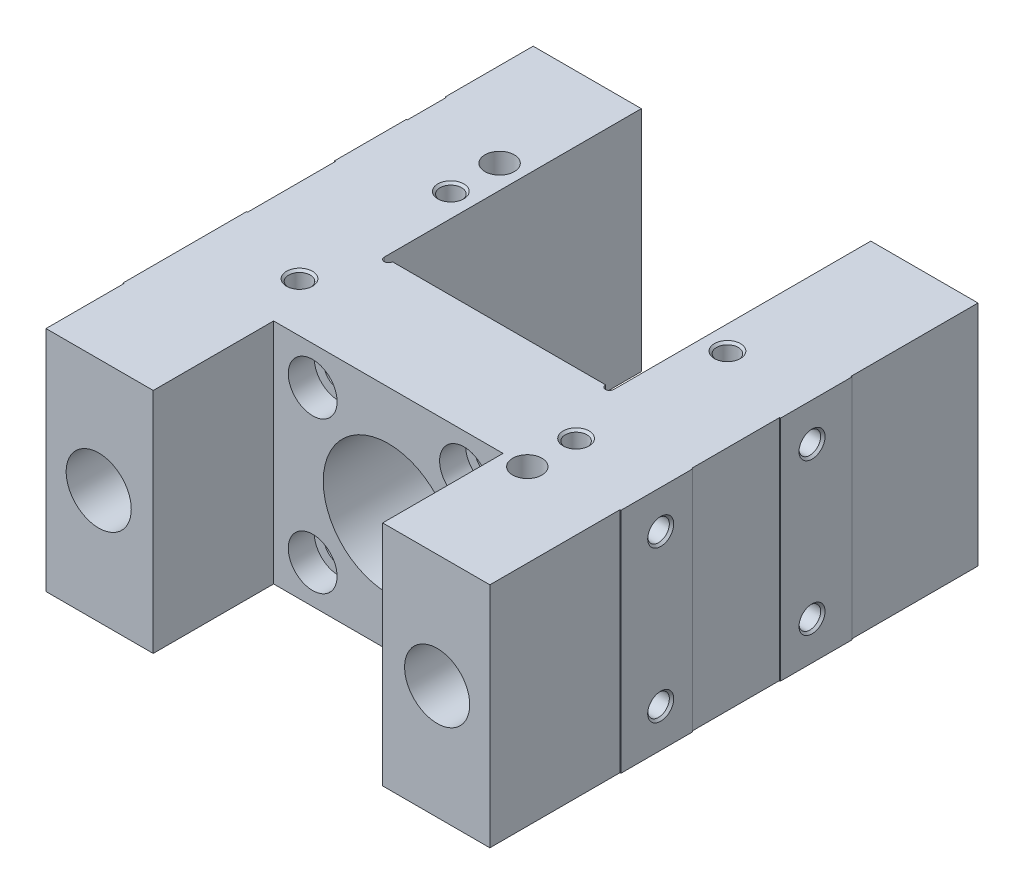
from build123d import *

# Parameters (mm, degrees)
BOSS_EXTRUDE1_DEPTH      = 35
BOSS_EXTRUDE1_DEPTH_BACK = 35
SKETCH2_W                = 36
SKETCH2_H                = 20
HOLE1_D                  = 6.647
HOLE1_DEPTH              = 19.414509714
HOLE1_CSINK_D            = 8
HOLE1_CSINK_ANGLE        = 90
HOLE1_TIP                = 1.91882362
HOLE2_D                  = 6.647
HOLE2_DEPTH              = 19.414509714
HOLE2_CSINK_D            = 8
HOLE2_CSINK_ANGLE        = 90
HOLE2_TIP                = 1.91882362
HOLE3_D                  = 6.647
HOLE3_DEPTH              = 19.414509714
HOLE3_CSINK_D            = 8
HOLE3_CSINK_ANGLE        = 90
HOLE3_TIP                = 1.91882362
SKETCH26_R               = 10
CUT_EXTRUDE1_DEPTH       = 150
SKETCH27_R               = 10
CUT_EXTRUDE2_DEPTH       = 150
CUT_EXTRUDE3_DEPTH       = 70
CUT_EXTRUDE3_DEPTH_BACK  = 70
SKETCH28_W               = 177
SKETCH28_H               = 190
SKETCH29_R               = 4.5
CUT_EXTRUDE4_DEPTH       = 17.5


with BuildPart() as part:
    # Sketch1 → Boss-Extrude1 (new, two sides: drawn at the far end of the back side and taken through both)
    with BuildSketch(Plane(origin=(0, 0, 0), x_dir=(1, 0, 0), z_dir=(0, 1, 0)).offset(-BOSS_EXTRUDE1_DEPTH_BACK)):
        with BuildLine():
            Line((-68.5, -71), (-35.25, -71))
            Line((-35.25, -71), (-35.25, -34))
            Line((-35.25, -34), (35.25, -34))
            Line((35.25, -34), (35.25, -71))
            Line((35.25, -71), (68.5, -71))
            Line((68.5, -71), (68.5, 79))
            Line((68.5, 79), (35.25, 79))
            Line((35.25, 79), (35.25, 0))
            ThreePointArc((35.25, 0), (34, -1.25), (32.75, 0))
            Line((32.75, 0), (-32.75, 0))
            ThreePointArc((-32.75, 0), (-34, -1.25), (-35.25, 0))
            Line((-35.25, 0), (-35.25, 79))
            Line((-35.25, 79), (-68.5, 79))
            Line((-68.5, 79), (-68.5, -71))
        make_face()
    extrude(amount=BOSS_EXTRUDE1_DEPTH + BOSS_EXTRUDE1_DEPTH_BACK)

    # Sketch2 → Cut-Revolve1 (revolve, cut)
    with BuildSketch(Plane(origin=(0, 0, 0), x_dir=(0, 0, -1), z_dir=(1, 0, 0))):
        with Locations((-17, 10)):
            Rectangle(SKETCH2_W, SKETCH2_H)
    revolve(axis=Axis((0, 0, -1), (0, 0, 1)), mode=Mode.SUBTRACT)

    # Sketch3 → Cut-Revolve2 (revolve, cut)
    with BuildSketch(Plane(origin=(-23.25, 0, 0), x_dir=(0, 0, -1), z_dir=(1, 0, 0))):
        Polygon((-34, 23.25), (-34, 30.75), (-26, 30.75), (-26, 27.75), (0, 27.75), (0, 23.25), align=None)
    revolve(axis=Axis((-23.25, 23.25, 0), (0, 0, 1)), mode=Mode.SUBTRACT)

    # Sketch4 → Cut-Revolve3 (revolve, cut)
    with BuildSketch(Plane(origin=(-23.25, 0, 0), x_dir=(0, 0, -1), z_dir=(1, 0, 0))):
        Polygon((-34, -23.25), (-34, -15.75), (-26, -15.75), (-26, -18.75), (0, -18.75), (0, -23.25), align=None)
    revolve(axis=Axis((-23.25, -23.25, 0), (0, 0, 1)), mode=Mode.SUBTRACT)

    # Sketch5 → Cut-Revolve4 (revolve, cut)
    with BuildSketch(Plane(origin=(23.25, 0, 0), x_dir=(0, 0, -1), z_dir=(1, 0, 0))):
        Polygon((-34, 23.25), (-34, 30.75), (-26, 30.75), (-26, 27.75), (0, 27.75), (0, 23.25), align=None)
    revolve(axis=Axis((23.25, 23.25, 0), (0, 0, 1)), mode=Mode.SUBTRACT)

    # Sketch6 → Cut-Revolve5 (revolve, cut)
    with BuildSketch(Plane(origin=(23.25, 0, 0), x_dir=(0, 0, -1), z_dir=(1, 0, 0))):
        Polygon((-34, -23.25), (-34, -15.75), (-26, -15.75), (-26, -18.75), (0, -18.75), (0, -23.25), align=None)
    revolve(axis=Axis((23.25, -23.25, 0), (0, 0, 1)), mode=Mode.SUBTRACT)

    # Hole1
    with Locations(Plane(origin=(0, 35, 0), x_dir=(1, 0, 0), z_dir=(0, 1, 0))):
        with Locations((42.5, -18.8)):
            CounterSinkHole(HOLE1_D / 2, HOLE1_CSINK_D / 2, depth=HOLE1_DEPTH, counter_sink_angle=HOLE1_CSINK_ANGLE)
            with Locations((0, 0, -(HOLE1_DEPTH + HOLE1_TIP / 2))):  # 120° drill point
                Cone(0, HOLE1_D / 2, HOLE1_TIP, mode=Mode.SUBTRACT)

    # Hole2
    with Locations(Plane(origin=(0, 35, 0), x_dir=(1, 0, 0), z_dir=(0, 1, 0))):
        with Locations((-42.5, -18.8)):
            CounterSinkHole(HOLE2_D / 2, HOLE2_CSINK_D / 2, depth=HOLE2_DEPTH, counter_sink_angle=HOLE2_CSINK_ANGLE)
            with Locations((0, 0, -(HOLE2_DEPTH + HOLE2_TIP / 2))):  # 120° drill point
                Cone(0, HOLE2_D / 2, HOLE2_TIP, mode=Mode.SUBTRACT)

    # Sketch11 → Cut-Revolve6 (revolve, cut)
    with BuildSketch(Plane.XY.offset(18.8)):
        Polygon((48.5, 23.25), (50.41882362, 26.5735), (67.8235, 26.5735), (68.5, 27.25), (68.5, 23.25), align=None)
    revolve(axis=Axis((68.5, 23.25, 18.8), (-1, 0, 0)), mode=Mode.SUBTRACT)

    # Sketch12 → Cut-Revolve7 (revolve, cut)
    with BuildSketch(Plane.XY.offset(18.8)):
        Polygon((48.5, -23.25), (50.41882362, -19.9265), (67.8235, -19.9265), (68.5, -19.25), (68.5, -23.25), align=None)
    revolve(axis=Axis((68.5, -23.25, 18.8), (-1, 0, 0)), mode=Mode.SUBTRACT)

    # Sketch13 → Cut-Revolve8 (revolve, cut)
    with BuildSketch(Plane.XY.offset(18.8)):
        Polygon((-68.5, 23.25), (-68.5, 27.25), (-67.8235, 26.5735), (-50.41882362, 26.5735), (-48.5, 23.25), align=None)
    revolve(axis=Axis((-48.5, 23.25, 18.8), (-1, 0, 0)), mode=Mode.SUBTRACT)

    # Sketch14 → Cut-Revolve9 (revolve, cut)
    with BuildSketch(Plane.XY.offset(18.8)):
        Polygon((-68.5, -23.25), (-68.5, -19.25), (-67.8235, -19.9265), (-50.41882362, -19.9265), (-48.5, -23.25), align=None)
    revolve(axis=Axis((-48.5, -23.25, 18.8), (-1, 0, 0)), mode=Mode.SUBTRACT)

    # Hole3
    with Locations(Plane(origin=(0, 35, 0), x_dir=(1, 0, 0), z_dir=(0, 1, 0))):
        with Locations((42.5, 27.7)):
            CounterSinkHole(HOLE3_D / 2, HOLE3_CSINK_D / 2, depth=HOLE3_DEPTH, counter_sink_angle=HOLE3_CSINK_ANGLE)
            with Locations((0, 0, -(HOLE3_DEPTH + HOLE3_TIP / 2))):  # 120° drill point
                Cone(0, HOLE3_D / 2, HOLE3_TIP, mode=Mode.SUBTRACT)

    # Sketch17 → Cut-Revolve10 (revolve, cut)
    with BuildSketch(Plane.XY.offset(-27.7)):
        Polygon((-42.5, 35), (-38.5, 35), (-39.1765, 34.3235), (-39.1765, 15.585490286), (-42.5, 13.666666667), align=None)
    revolve(axis=Axis((-42.5, 13.666666667, -27.7), (0, 1, 0)), mode=Mode.SUBTRACT)

    # Sketch18 → Cut-Revolve11 (revolve, cut)
    with BuildSketch(Plane.XY.offset(-27.7)):
        Polygon((48.5, 23.25), (50.41882362, 26.5735), (67.8235, 26.5735), (68.5, 27.25), (68.5, 23.25), align=None)
    revolve(axis=Axis((68.5, 23.25, -27.7), (-1, 0, 0)), mode=Mode.SUBTRACT)

    # Sketch19 → Cut-Revolve12 (revolve, cut)
    with BuildSketch(Plane.XY.offset(-27.7)):
        Polygon((48.5, -23.25), (50.41882362, -19.9265), (67.8235, -19.9265), (68.5, -19.25), (68.5, -23.25), align=None)
    revolve(axis=Axis((68.5, -23.25, -27.7), (-1, 0, 0)), mode=Mode.SUBTRACT)

    # Sketch20 → Cut-Revolve13 (revolve, cut)
    with BuildSketch(Plane.XY.offset(-27.7)):
        Polygon((-68.5, 23.25), (-68.5, 27.25), (-67.8235, 26.5735), (-50.41882362, 26.5735), (-48.5, 23.25), align=None)
    revolve(axis=Axis((-48.5, 23.25, -27.7), (-1, 0, 0)), mode=Mode.SUBTRACT)

    # Sketch21 → Cut-Revolve14 (revolve, cut)
    with BuildSketch(Plane.XY.offset(-27.7)):
        Polygon((-68.5, -23.25), (-68.5, -19.25), (-67.8235, -19.9265), (-50.41882362, -19.9265), (-48.5, -23.25), align=None)
    revolve(axis=Axis((-48.5, -23.25, -27.7), (-1, 0, 0)), mode=Mode.SUBTRACT)

    # Sketch22 → Cut-Revolve15 (revolve, cut)
    with BuildSketch(Plane.XY.offset(-63)):
        Polygon((-68.5, 23.25), (-68.5, 27.25), (-67.8235, 26.5735), (-50.41882362, 26.5735), (-48.5, 23.25), align=None)
    revolve(axis=Axis((-48.5, 23.25, -63), (-1, 0, 0)), mode=Mode.SUBTRACT)

    # Sketch23 → Cut-Revolve16 (revolve, cut)
    with BuildSketch(Plane.XY.offset(-63)):
        Polygon((-68.5, -23.25), (-68.5, -19.25), (-67.8235, -19.9265), (-50.41882362, -19.9265), (-48.5, -23.25), align=None)
    revolve(axis=Axis((-48.5, -23.25, -63), (-1, 0, 0)), mode=Mode.SUBTRACT)

    # Sketch24 → Cut-Revolve17 (revolve, cut)
    with BuildSketch(Plane.XY.offset(37)):
        Polygon((-68.5, 23.25), (-68.5, 27.25), (-67.8235, 26.5735), (-50.41882362, 26.5735), (-48.5, 23.25), align=None)
    revolve(axis=Axis((-48.5, 23.25, 37), (-1, 0, 0)), mode=Mode.SUBTRACT)

    # Sketch25 → Cut-Revolve18 (revolve, cut)
    with BuildSketch(Plane.XY.offset(37)):
        Polygon((-68.5, -23.25), (-68.5, -19.25), (-67.8235, -19.9265), (-50.41882362, -19.9265), (-48.5, -23.25), align=None)
    revolve(axis=Axis((-48.5, -23.25, 37), (-1, 0, 0)), mode=Mode.SUBTRACT)

    # Sketch26 → Cut-Extrude1 (cut)
    with BuildSketch(Plane.XY.offset(-79)):
        with Locations((52, 0)):
            Circle(SKETCH26_R)
    extrude(amount=CUT_EXTRUDE1_DEPTH, mode=Mode.SUBTRACT)

    # Sketch27 → Cut-Extrude2 (cut)
    with BuildSketch(Plane.XY.offset(-79)):
        with Locations((-52, 0)):
            Circle(SKETCH27_R)
    extrude(amount=CUT_EXTRUDE2_DEPTH, mode=Mode.SUBTRACT)

    # Sketch28 → Cut-Extrude3 (cut, two sides: drawn at the far end of the back side and taken through both)
    with BuildSketch(Plane(origin=(0, 0, 0), x_dir=(1, 0, 0), z_dir=(0, 1, 0)).offset(-CUT_EXTRUDE3_DEPTH_BACK)):
        with Locations((0, 4)):
            Rectangle(SKETCH28_W, SKETCH28_H)
        Polygon((-68.5, 18), (-68.2, 18), (-68.2, -9), (-68.5, -9), (-68.5, -47), (-68.2, -47), (-68.2, -71), (68.2, -71), (68.2, -31), (68.5, -31), (68.5, -9), (68.2, -9), (68.2, 18), (68.5, 18), (68.5, 40), (68.2, 40), (68.2, 79), (-68.5, 79), (-68.5, 52), (-68.2, 52), (-68.2, 40), (-68.5, 40), align=None, mode=Mode.SUBTRACT)
    extrude(amount=CUT_EXTRUDE3_DEPTH + CUT_EXTRUDE3_DEPTH_BACK, mode=Mode.SUBTRACT)

    # Sketch29 → Cut-Extrude4 (cut)
    with BuildSketch(Plane(origin=(0, 35, 0), x_dir=(1, 0, 0), z_dir=(0, 1, 0))):
        with Locations((-42.5, 42.7)):
            Circle(SKETCH29_R)
        with Locations((42.5, -33.8)):
            Circle(SKETCH29_R)
    extrude(amount=-CUT_EXTRUDE4_DEPTH, mode=Mode.SUBTRACT)


solid = part.part
